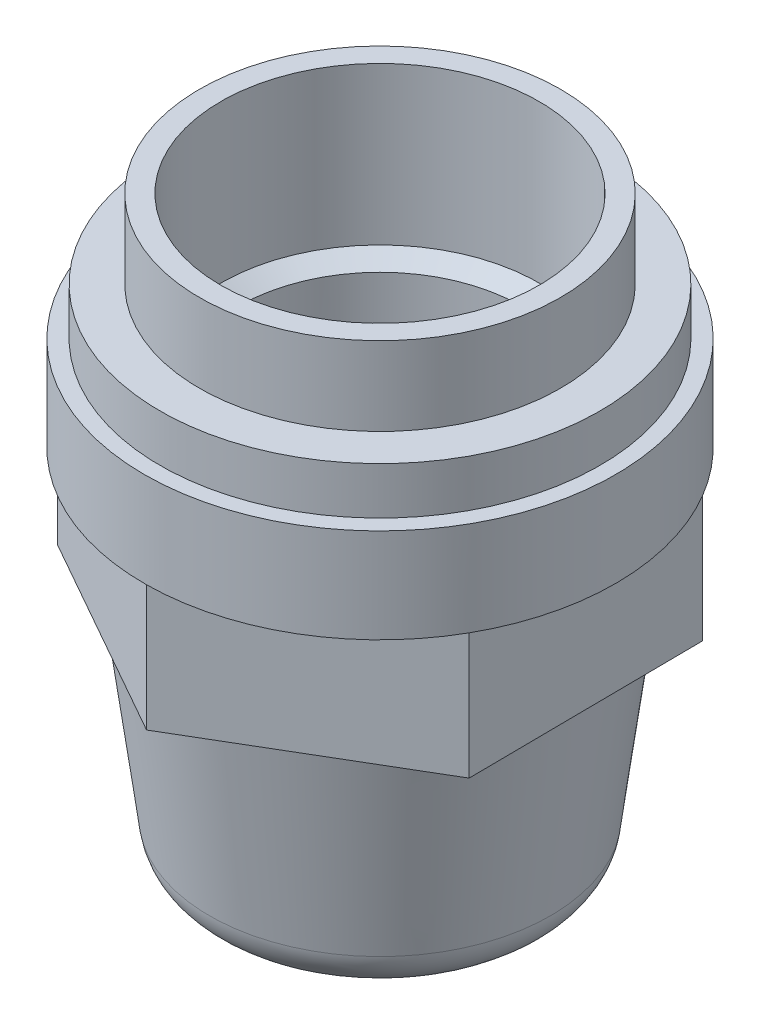
from build123d import *

# Parameters (mm, degrees)
SKETCH_4_R             = 12.471621376
EXTRUDE_2_DEPTH        = 8
SKETCH_6_R             = 8.974783973
EXTRUDE_3_DEPTH        = 8
HOLE_WIZARD_M201_D     = 20.25
HOLE_WIZARD_M201_DEPTH = 10
HOLE_WIZARD_M201_TIP   = 6.083713768


with BuildPart() as part:
    # Эскиз2 → Повернуть1 (revolve)
    with BuildSketch(Plane.XY):
        with BuildLine():
            Line((-4.5, 0.130191103), (-7.868865891, 0.130191103))
            ThreePointArc((-7.868865891, 0.130191103), (-9.846990335, 0.874747979), (-10.843230675, 2.73884198))
            Line((-10.843230675, 2.73884198), (-12.471621376, 15.115075065))
            Line((-12.471621376, 15.115075065), (-12.471621376, 23.115075065))
            Line((-12.471621376, 23.115075065), (-14.984883962, 23.115075065))
            Line((-14.984883962, 23.115075065), (-14.984883962, 29.115075065))
            Line((-14.984883962, 29.115075065), (-13.983803036, 29.115075065))
            Line((-13.983803036, 29.115075065), (-13.983803036, 32.115075065))
            Line((-13.983803036, 32.115075065), (-11.48027645, 32.115075065))
            Line((-11.48027645, 32.115075065), (-11.48027645, 37.115075065))
            Line((-11.48027645, 37.115075065), (-8.974783973, 37.115075065))
            Line((-8.974783973, 37.115075065), (-8.974783973, 23.115075065))
            Line((-8.974783973, 23.115075065), (-6.974783973, 23.115075065))
            Line((-6.974783973, 23.115075065), (-6.974783973, 18.115075065))
            Line((-6.974783973, 18.115075065), (-4.449353589, 18.115075065))
            Line((-4.449353589, 18.115075065), (-4.490567157, 3.479857527))
            Line((-4.490567157, 3.479857527), (-6.488062408, 3.489211927))
            Line((-6.488062408, 3.489211927), (-6.49087648, 2.489915788))
            Line((-6.49087648, 2.489915788), (-4.493381229, 2.480561388))
            Line((-4.493381229, 2.480561388), (-4.5, 0.130191103))
        make_face()
    revolve(axis=Axis((0, 0, 0), (0, 1, 0)))

    # Эскиз4 → Бобышка-Вытянуть2 (add)
    with BuildSketch(Plane(origin=(0, 23.115075065, 0), x_dir=(-1, 0, 0), z_dir=(0, -1, 0))):
        Polygon((-13.044923547, -7.374057026), (-0.13634106, -14.984263695), (12.908582486, -7.610206669), (13.044923547, 7.374057026), (0.13634106, 14.984263695), (-12.908582486, 7.610206669), align=None)
        Circle(SKETCH_4_R, mode=Mode.SUBTRACT)
    extrude(amount=EXTRUDE_2_DEPTH)

    # Эскиз6 → Бобышка-Вытянуть3 (add)
    with BuildSketch(Plane(origin=(0, 37.115075065, 0), x_dir=(1, 0, 0), z_dir=(0, 1, 0))):
        Circle(SKETCH_6_R)
    extrude(amount=-EXTRUDE_3_DEPTH)

    # Сверло под метчик  спиральное M201
    with Locations(Plane(origin=(0, 37.115075065, 0), x_dir=(1, 0, 0), z_dir=(0, 1, 0))):
        with Locations((0, 0)):
            Hole(HOLE_WIZARD_M201_D / 2, depth=HOLE_WIZARD_M201_DEPTH)
            with Locations((0, 0, -(HOLE_WIZARD_M201_DEPTH + HOLE_WIZARD_M201_TIP / 2))):  # 118° drill point
                Cone(0, HOLE_WIZARD_M201_D / 2, HOLE_WIZARD_M201_TIP, mode=Mode.SUBTRACT)


solid = part.part
